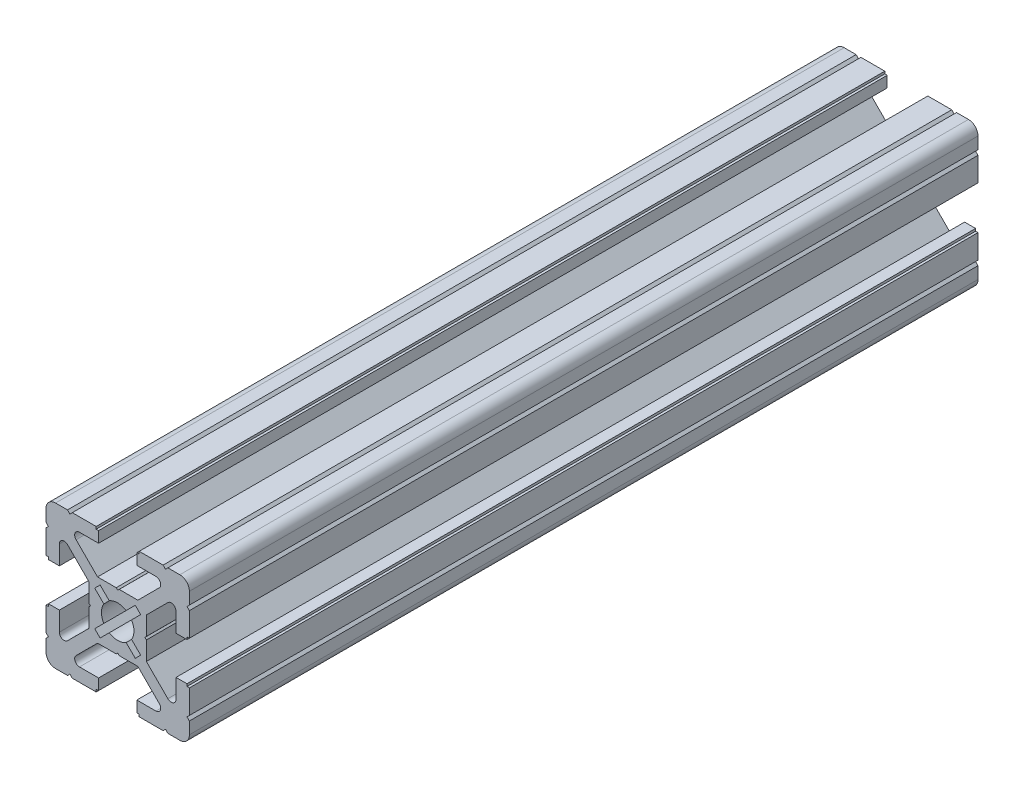
from build123d import *

# Parameters (mm, degrees)
BOSS_EXTRUDE1_DEPTH = 165


with BuildPart() as part:
    # Sketch1 → Boss-Extrude1 (new body)
    with BuildSketch(Plane(origin=(0, 0, -65), x_dir=(-1, 0, 0), z_dir=(0, 0, -1))):
        with BuildLine():
            Line((-14.999999999, 12.999999999), (-14.999999999, 10.499999999))
            Line((-14.999999999, 10.499999999), (-14.499999999, 9.999999999))
            Line((-14.499999999, 9.999999999), (-14.999999999, 9.5))
            Line((-14.999999999, 9.5), (-14.999999999, 4.5))
            Line((-14.999999999, 4.5), (-14.5, 4.5))
            Line((-14.5, 4.5), (-14.5, 4))
            Line((-14.5, 4), (-12.200000005, 4))
            Line((-12.200000005, 4), (-12.200000005, 7.999999995))
            ThreePointArc((-12.200000005, 7.999999995), (-11.582683434, 8.923879532), (-10.492893215, 8.70710678))
            Line((-10.492893215, 8.70710678), (-6, 4.214213564))
            Line((-6, 4.214213564), (-6, 0.312520903))
            Line((-6, 0.312520903), (-5.7, 0))
            Line((-5.7, 0), (-6, -0.312520901))
            Line((-6, -0.312520901), (-6, -4.214213564))
            Line((-6, -4.214213564), (-10.492893215, -8.70710678))
            ThreePointArc((-10.492893215, -8.70710678), (-11.582683434, -8.923879532), (-12.200000005, -7.999999995))
            Line((-12.200000005, -7.999999995), (-12.200000005, -4))
            Line((-12.200000005, -4), (-14.5, -4))
            Line((-14.5, -4), (-14.5, -4.5))
            Line((-14.5, -4.5), (-14.999999999, -4.5))
            Line((-14.999999999, -4.5), (-14.999999999, -9.500000003))
            Line((-14.999999999, -9.500000003), (-14.499999999, -10.000000002))
            Line((-14.499999999, -10.000000002), (-14.999999999, -10.500000001))
            Line((-14.999999999, -10.500000001), (-14.999999999, -13))
            ThreePointArc((-14.999999999, -13), (-14.414213561, -14.414213562), (-12.999999999, -15))
            Line((-12.999999999, -15), (-10.5, -15))
            Line((-10.5, -15), (-10.000000001, -14.500000001))
            Line((-10.000000001, -14.500000001), (-9.500000001, -15))
            Line((-9.500000001, -15), (-4.5, -15))
            Line((-4.5, -15), (-4.5, -14.5))
            Line((-4.5, -14.5), (-4, -14.5))
            Line((-4, -14.5), (-4, -12.200000005))
            Line((-4, -12.200000005), (-7.999999995, -12.200000005))
            ThreePointArc((-7.999999995, -12.200000005), (-8.923879532, -11.582683434), (-8.70710678, -10.492893215))
            Line((-8.70710678, -10.492893215), (-4.214213564, -6))
            Line((-4.214213564, -6), (-0.312520903, -6))
            Line((-0.312520903, -6), (0, -5.7))
            Line((0, -5.7), (0.312520901, -6))
            Line((0.312520901, -6), (4.214213564, -6))
            Line((4.214213564, -6), (8.70710678, -10.492893215))
            ThreePointArc((8.70710678, -10.492893215), (8.923879532, -11.582683434), (7.999999995, -12.200000005))
            Line((7.999999995, -12.200000005), (4, -12.200000005))
            Line((4, -12.200000005), (4, -14.5))
            Line((4, -14.5), (4.5, -14.5))
            Line((4.5, -14.5), (4.5, -15))
            Line((4.5, -15), (9.500000001, -15))
            Line((9.500000001, -15), (9.989897949, -14.5))
            Line((9.989897949, -14.5), (10.489897949, -15))
            Line((10.489897949, -15), (13, -15))
            ThreePointArc((13, -15), (14.414213562, -14.414213562), (15, -13))
            Line((15, -13), (15, -10.5))
            Line((15, -10.5), (14.500000001, -10.000000001))
            Line((14.500000001, -10.000000001), (15, -9.500000001))
            Line((15, -9.500000001), (15, -4.5))
            Line((15, -4.5), (14.5, -4.5))
            Line((14.5, -4.5), (14.5, -4))
            Line((14.5, -4), (12.200000005, -4))
            Line((12.200000005, -4), (12.200000005, -7.999999995))
            ThreePointArc((12.200000005, -7.999999995), (11.582683434, -8.923879532), (10.492893215, -8.70710678))
            Line((10.492893215, -8.70710678), (6, -4.214213564))
            Line((6, -4.214213564), (6, -0.312520903))
            Line((6, -0.312520903), (5.7, 0))
            Line((5.7, 0), (6, 0.312520901))
            Line((6, 0.312520901), (6, 4.214213564))
            Line((6, 4.214213564), (10.492893215, 8.707106779))
            ThreePointArc((10.492893215, 8.707106779), (11.582683434, 8.923879532), (12.200000005, 7.999999994))
            Line((12.200000005, 7.999999994), (12.200000005, 4))
            Line((12.200000005, 4), (14.5, 4))
            Line((14.5, 4), (14.5, 4.5))
            Line((14.5, 4.5), (15, 4.5))
            Line((15, 4.5), (15, 9.500000001))
            Line((15, 9.500000001), (14.500000001, 10.000000001))
            Line((14.500000001, 10.000000001), (15, 10.5))
            Line((15, 10.5), (15, 12.999999999))
            ThreePointArc((15, 12.999999999), (14.414213562, 14.414213561), (13, 14.999999999))
            Line((13, 14.999999999), (10.500000001, 14.999999999))
            Line((10.500000001, 14.999999999), (10.000000002, 14.499999999))
            Line((10.000000002, 14.499999999), (9.500000003, 14.999999999))
            Line((9.500000003, 14.999999999), (4.5, 14.999999999))
            Line((4.5, 14.999999999), (4.5, 14.5))
            Line((4.5, 14.5), (4, 14.5))
            Line((4, 14.5), (4, 12.200000005))
            Line((4, 12.200000005), (7.999999995, 12.200000005))
            ThreePointArc((7.999999995, 12.200000005), (8.923879532, 11.582683434), (8.70710678, 10.492893215))
            Line((8.70710678, 10.492893215), (4.214213564, 6))
            Line((4.214213564, 6), (0.312520903, 6))
            Line((0.312520903, 6), (0, 5.7))
            Line((0, 5.7), (-0.312520901, 6))
            Line((-0.312520901, 6), (-4.214213564, 6))
            Line((-4.214213564, 6), (-8.707106779, 10.492893215))
            ThreePointArc((-8.707106779, 10.492893215), (-8.923879532, 11.582683434), (-7.999999994, 12.200000005))
            Line((-7.999999994, 12.200000005), (-4, 12.200000005))
            Line((-4, 12.200000005), (-4, 14.5))
            Line((-4, 14.5), (-4.5, 14.5))
            Line((-4.5, 14.5), (-4.5, 14.999999999))
            Line((-4.5, 14.999999999), (-9.5, 14.999999999))
            Line((-9.5, 14.999999999), (-9.999999999, 14.499999999))
            Line((-9.999999999, 14.499999999), (-10.499999999, 14.999999999))
            Line((-10.499999999, 14.999999999), (-12.999999999, 14.999999999))
            ThreePointArc((-12.999999999, 14.999999999), (-14.414213561, 14.414213561), (-14.999999999, 12.999999999))
        make_face()
        with BuildLine():
            Line((4.808326112, 3.676955262), (2.902349714, 1.770978864))
            ThreePointArc((2.902349714, 1.770978864), (3.4, 0), (2.902349714, -1.770978864))
            Line((2.902349714, -1.770978864), (4.808326112, -3.676955262))
            Line((4.808326112, -3.676955262), (3.676955262, -4.808326112))
            Line((3.676955262, -4.808326112), (1.770978864, -2.902349714))
            ThreePointArc((1.770978864, -2.902349714), (0, -3.4), (-1.770978864, -2.902349714))
            Line((-1.770978864, -2.902349714), (-3.676955262, -4.808326112))
            Line((-3.676955262, -4.808326112), (-4.808326112, -3.676955262))
            Line((-4.808326112, -3.676955262), (-2.902349714, -1.770978864))
            ThreePointArc((-2.902349714, -1.770978864), (-3.4, 0), (-2.902349714, 1.770978864))
            Line((-2.902349714, 1.770978864), (-4.808326112, 3.676955262))
            Line((-4.808326112, 3.676955262), (-3.676955262, 4.808326112))
            Line((-3.676955262, 4.808326112), (-1.770978864, 2.902349714))
            ThreePointArc((-1.770978864, 2.902349714), (0, 3.4), (1.770978864, 2.902349714))
            Line((1.770978864, 2.902349714), (3.676955262, 4.808326112))
            Line((3.676955262, 4.808326112), (4.808326112, 3.676955262))
        make_face(mode=Mode.SUBTRACT)
    extrude(amount=-BOSS_EXTRUDE1_DEPTH)


solid = part.part
